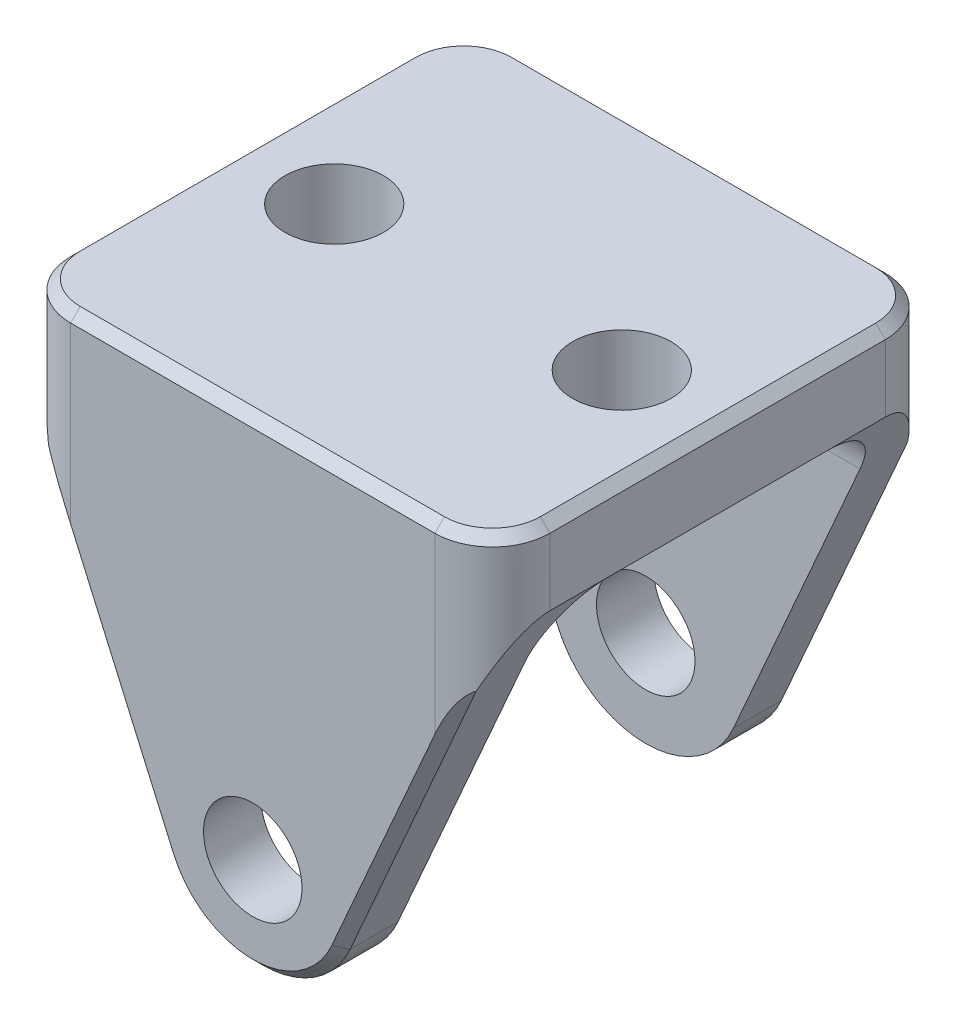
from build123d import *

# Parameters (mm, degrees)
BULK_TRIANGLE_DEPTH      = 14.9225
BULK_TRIANGLE_DEPTH_BACK = 14.9225
U_CUTOUT_DEPTH           = 627.44103
U_CUTOUT_DEPTH_BACK      = 627.44103
F_1_4_CLEARANCE_HOLE1_D  = 6.5278
F_1_4_CLEARANCE_HOLE2_D  = 6.5278
INNER_FILLET_R           = 3.81
TRIANGLE_DEBURR_SIZE     = 0.635
OUTER_FILLET_R           = 3.81
CLAMP_FACE_DEBURR_SIZE   = 0.635


with BuildPart() as part:
    # Sketch1 → Bulk Triangle (new, two sides)
    with BuildSketch(Plane.XY.offset(291.592)) as bulk_triangle_sk:
        with BuildLine():
            Line((9.42744, 518.143313), (-0.635, 541.02))
            Line((-0.635, 541.02), (-0.635, 546.1))
            Line((-0.635, 546.1), (31.115, 546.1))
            Line((31.115, 546.1), (31.115, 541.02))
            Line((31.115, 541.02), (21.05256, 518.143313))
            ThreePointArc((21.05256, 518.143313), (15.24, 514.35), (9.42744, 518.143313))
        make_face()
    extrude(amount=BULK_TRIANGLE_DEPTH)
    extrude(bulk_triangle_sk.sketch, amount=-BULK_TRIANGLE_DEPTH_BACK)

    # Sketch3 → U-Cutout (cut, two sides)
    with BuildSketch(Plane(origin=(15.24, 0, 0), x_dir=(0, -4.31797119152115e-05, -0.9999999990677564), z_dir=(1, 0, 0))) as u_cutout_sk:
        Polygon((-302.727861, 541.006929), (-302.726709, 514.336929), (-280.501709, 514.337888), (-280.502861, 541.007888), align=None)
    extrude(amount=U_CUTOUT_DEPTH, mode=Mode.SUBTRACT)
    extrude(u_cutout_sk.sketch, amount=-U_CUTOUT_DEPTH_BACK, mode=Mode.SUBTRACT)

    # 1/4 Clearance Hole1 (through all)
    with Locations(Plane(origin=(15.24, 520.7, 306.5145), x_dir=(1, 0, 0), z_dir=(0, 0, 1))):
        with Locations((0, 0)):
            Hole(F_1_4_CLEARANCE_HOLE1_D / 2)

    # 1/4 Clearance Hole2 (through all)
    with Locations(Plane(origin=(24.765, 541.02, 291.592), x_dir=(-1, 0, 0), z_dir=(0, -1, 0))):
        with Locations((0, 0), (19.05, 0)):
            Hole(F_1_4_CLEARANCE_HOLE2_D / 2)

    # Inner Fillet
    inner_fillet_edges = [part.edges().sort_by_distance(p)[0] for p in [
        (15.24, 541.02, 280.4795),
        (15.24, 541.02, 302.7045),
    ]]
    fillet(inner_fillet_edges, radius=INNER_FILLET_R)

    # Triangle Deburr
    triangle_deburr_edges = [part.edges().sort_by_distance(p)[0] for p in [
        (15.24, 514.35, 276.6695),
        (4.39622, 529.581656, 276.6695),
        (26.08378, 529.581656, 276.6695),
        (4.39622, 529.581656, 306.5145),
        (15.24, 514.35, 306.5145),
        (26.08378, 529.581656, 306.5145),
    ]]
    chamfer(triangle_deburr_edges, length=TRIANGLE_DEBURR_SIZE)

    # Outer Fillet
    outer_fillet_edges = [part.edges().sort_by_distance(p)[0] for p in [
        (-0.635, 544.348569, 276.6695),
        (31.115, 544.348569, 276.6695),
        (-0.635, 544.348569, 306.5145),
        (31.115, 544.348569, 306.5145),
    ]]
    fillet(outer_fillet_edges, radius=OUTER_FILLET_R)

    # Clamp Face Deburr
    clamp_face_deburr_edges = [part.edges().sort_by_distance(p)[0] for p in [
        (-0.635, 546.1, 291.592),
        (15.24, 546.1, 276.6695),
        (31.115, 546.1, 291.592),
        (15.24, 546.1, 306.5145),
        (29.999077, 546.1, 305.398577),
        (0.480923, 546.1, 305.398577),
        (29.999077, 546.1, 277.785423),
        (0.480923, 546.1, 277.785423),
    ]]
    chamfer(clamp_face_deburr_edges, length=CLAMP_FACE_DEBURR_SIZE)


solid = part.part
